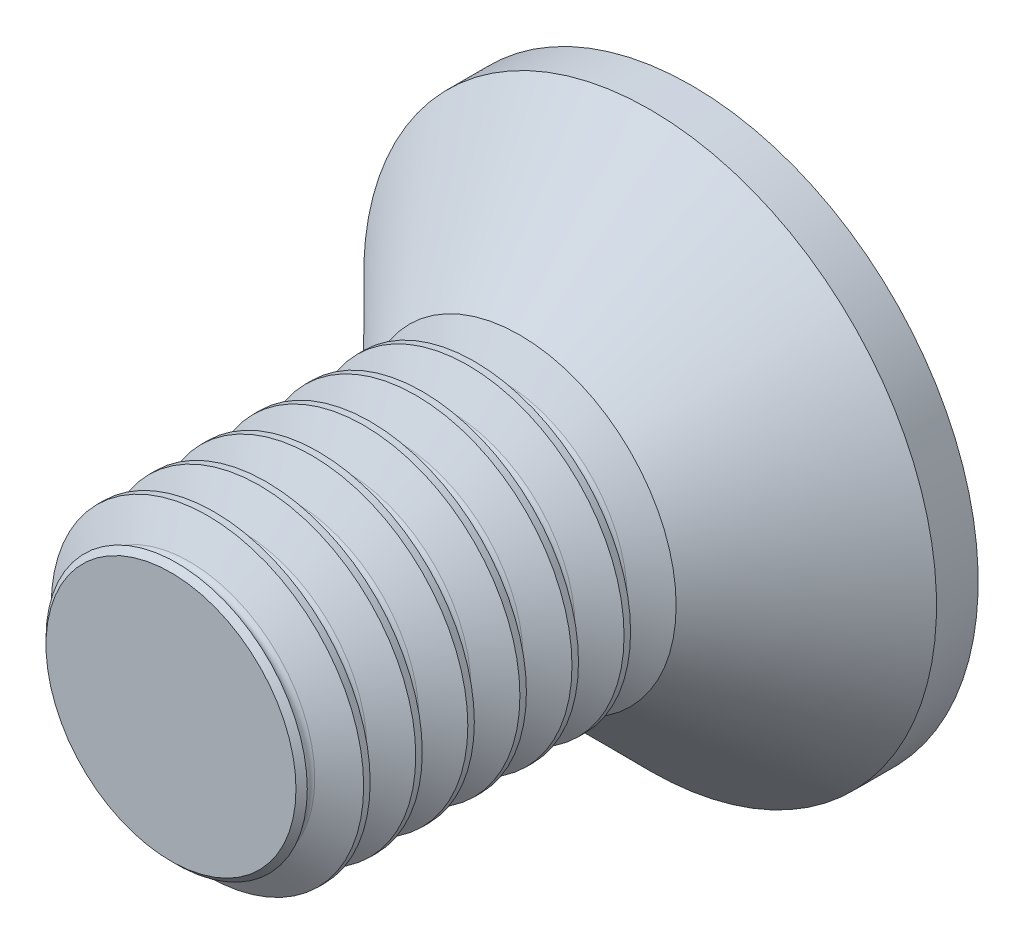
from build123d import *

# Parameters (mm, degrees)
SKETCH5_W           = 5
SKETCH5_H           = 1.5
THREAD_SIMPLE_COUNT = 7
THREAD_SIMPLE_PITCH = 0.5
SKETCH15_W          = 1.65
SKETCH15_H          = 2.75
CUT_HEAD_KEY_DEPTH  = 0.825


with BuildPart() as part:
    # Sketch5 → body (revolve)
    with BuildSketch(Plane(origin=(0, 0, 0), x_dir=(0, 0, -1), z_dir=(1, 0, 0))):
        with Locations((-2.5, 0.75)):
            Rectangle(SKETCH5_W, SKETCH5_H)
    revolve(axis=Axis((0, 0, 5), (0, 0, -1)))

    # Sketch11 → cut-chamfer-start (revolve, cut)
    with BuildSketch(Plane(origin=(0, 0, 0), x_dir=(0, 0, -1), z_dir=(1, 0, 0))):
        Polygon((-5, -1.5), (-5, -1.2), (-4.7, -1.5), align=None)
    revolve(axis=Axis((0, 0, 5), (0, 0, -1)), mode=Mode.SUBTRACT)

    # Sketch8 → thread-single (revolve, cut)
    with BuildSketch(Plane(origin=(0, 0, 0), x_dir=(0, 0, -1), z_dir=(1, 0, 0))):
        with BuildLine():
            Line((-2.0875, -1.5), (-1.65, -1.5))
            Line((-1.65, -1.5), (-1.821875, -1.202303767))
            ThreePointArc((-1.821875, -1.202303767), (-1.86875, -1.175240474), (-1.915625, -1.202303767))
            Line((-1.915625, -1.202303767), (-2.0875, -1.5))
        make_face()
    thread_single = revolve(axis=Axis((0, 0, 5), (0, 0, -1)), mode=Mode.SUBTRACT)

    # thread-simple: thread-single ×7
    with Locations(*[(0, 0, i * THREAD_SIMPLE_PITCH) for i in range(1, THREAD_SIMPLE_COUNT)]):
        add(thread_single, mode=Mode.SUBTRACT)

    # Sketch15 → body-head (revolve)
    with BuildSketch(Plane(origin=(0, 0, 0), x_dir=(0, 0, -1), z_dir=(1, 0, 0))):
        with Locations((-0.825, -1.375)):
            Rectangle(SKETCH15_W, SKETCH15_H)
    revolve(axis=Axis((0, 0, 0), (0, 0, 1)))

    # Sketch19 → cut-head-profile (revolve, cut)
    with BuildSketch(Plane(origin=(0, 0, 0), x_dir=(0, 0, -1), z_dir=(1, 0, 0))):
        Polygon((-1.65, -3.15), (-1.65, -1.5), (0, -3.15), align=None)
    revolve(axis=Axis((0, 0, 0), (0, 0, 1)), mode=Mode.SUBTRACT)

    # Sketch25 → cut-head-key (cut)
    with BuildSketch(Plane.XY):
        with BuildLine():
            ThreePointArc((0.182709695, 1.254833497), (0, 1.4), (-0.182709695, 1.254833497))
            ThreePointArc((-0.182709695, 1.254833497), (-0.487188951, 0.843836016), (-0.995362839, 0.785647986))
            ThreePointArc((-0.995362839, 0.785647986), (-1.212435565, 0.7), (-1.178072534, 0.469185512))
            ThreePointArc((-1.178072534, 0.469185512), (-0.974377901, 0), (-1.178072534, -0.469185512))
            ThreePointArc((-1.178072534, -0.469185512), (-1.212435565, -0.7), (-0.995362839, -0.785647986))
            ThreePointArc((-0.995362839, -0.785647986), (-0.487188951, -0.843836016), (-0.182709695, -1.254833497))
            ThreePointArc((-0.182709695, -1.254833497), (0, -1.4), (0.182709695, -1.254833497))
            ThreePointArc((0.182709695, -1.254833497), (0.487188951, -0.843836016), (0.995362839, -0.785647986))
            ThreePointArc((0.995362839, -0.785647986), (1.212435565, -0.7), (1.178072534, -0.469185512))
            ThreePointArc((1.178072534, -0.469185512), (0.974377901, 0), (1.178072534, 0.469185512))
            ThreePointArc((1.178072534, 0.469185512), (1.212435565, 0.7), (0.995362839, 0.785647986))
            ThreePointArc((0.995362839, 0.785647986), (0.487188951, 0.843836016), (0.182709695, 1.254833497))
        make_face()
    extrude(amount=CUT_HEAD_KEY_DEPTH, mode=Mode.SUBTRACT)


solid = part.part
